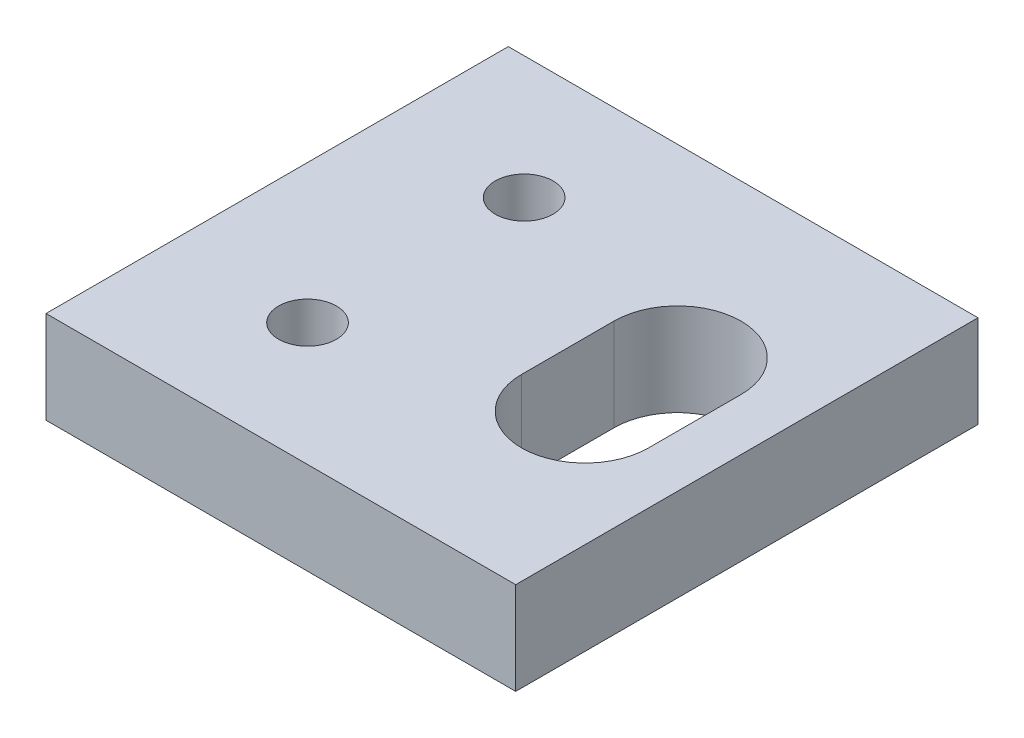
from build123d import *

# Parameters (mm, degrees)
SKETCH1_W           = 20.32
SKETCH1_H           = 20
SKETCH1_R           = 1.25
BOSS_EXTRUDE1_DEPTH = 4


with BuildPart() as part:
    # Sketch1 → Boss-Extrude1 (new body)
    with BuildSketch(Plane(origin=(0, 4, 0), x_dir=(1, 0, 0), z_dir=(0, 1, 0))):
        with Locations((10.16, -10)):
            Rectangle(SKETCH1_W, SKETCH1_H)
        with Locations((6, -14.686)):
            Circle(SKETCH1_R, mode=Mode.SUBTRACT)
        with Locations((6, -5.314)):
            Circle(SKETCH1_R, mode=Mode.SUBTRACT)
        with BuildLine():
            Line((12.57, -12), (12.57, -8))
            ThreePointArc((12.57, -8), (15.32, -5.25), (18.07, -8))
            Line((18.07, -8), (18.07, -12))
            ThreePointArc((18.07, -12), (15.32, -14.75), (12.57, -12))
        make_face(mode=Mode.SUBTRACT)
    extrude(amount=-BOSS_EXTRUDE1_DEPTH)


solid = part.part
